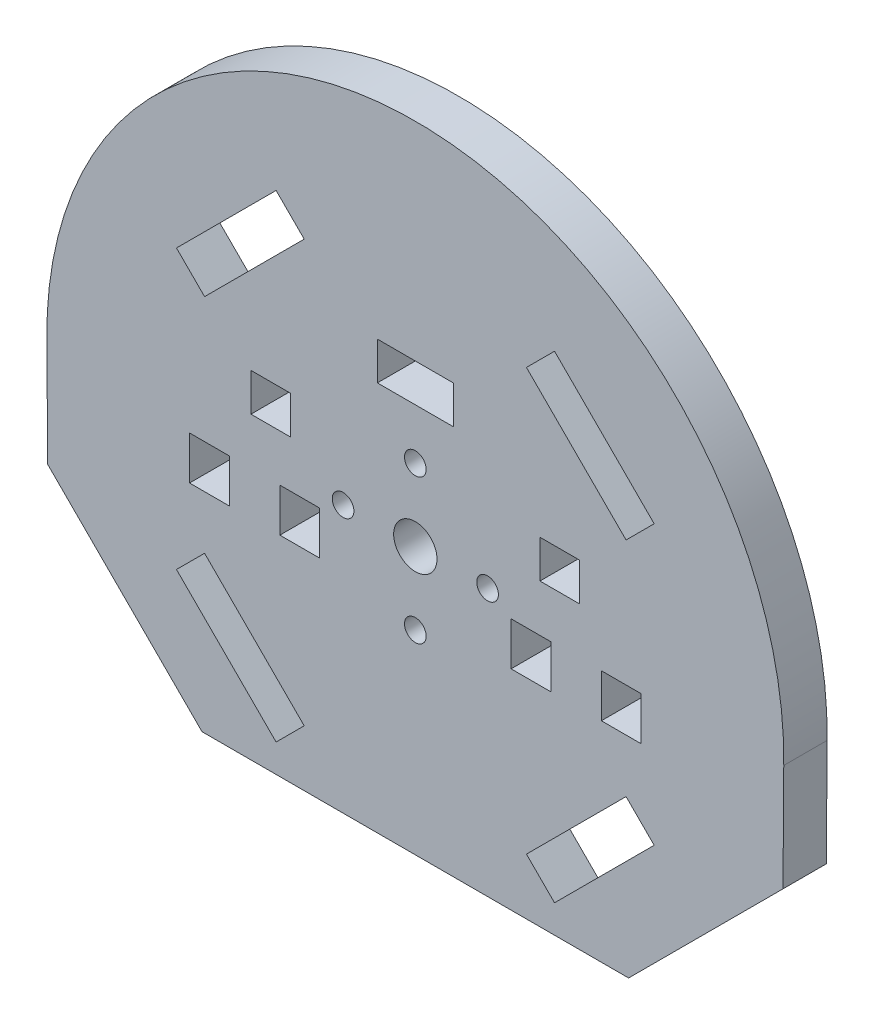
from build123d import *

# Parameters (mm, degrees)
MODEL_R             = 3
MODEL_R_2           = 1.5
MODEL_W             = 5.5
MODEL_H             = 5.25
BOSS_EXTRUDE1_DEPTH = 6


with BuildPart() as part:
    # Model → Boss-Extrude1 (new body)
    with BuildSketch(Plane.XY):
        with BuildLine():
            Line((97.092556574, 10.401311798), (38.049140345, 10.401311798))
            Line((38.049140345, 10.401311798), (16.682633066, 31.767819077))
            Line((16.682633066, 31.767819077), (16.576099155, 46.615832828))
            ThreePointArc((16.576099155, 46.615832828), (67.57084846, 98.347641115), (118.565597764, 46.615832828))
            Line((118.565597764, 46.615832828), (118.459063854, 31.767819077))
            Line((118.459063854, 31.767819077), (97.092556574, 10.401311798))
        make_face()
        with Locations((67.57084846, 47.347641115)):
            Circle(MODEL_R, mode=Mode.SUBTRACT)
        with Locations((67.57084846, 57.347641115)):
            Circle(MODEL_R_2, mode=Mode.SUBTRACT)
        with Locations((77.57084846, 47.347641115)):
            Circle(MODEL_R_2, mode=Mode.SUBTRACT)
        with Locations((67.57084846, 37.347641115)):
            Circle(MODEL_R_2, mode=Mode.SUBTRACT)
        with Locations((57.57084846, 47.347641115)):
            Circle(MODEL_R_2, mode=Mode.SUBTRACT)
        Polygon((45.296984853, 69.621504723), (52.191275969, 76.515795839), (48.302188673, 80.404883136), (34.513606439, 66.616300902), (38.402693736, 62.727213606), align=None, mode=Mode.SUBTRACT)
        Polygon((45.296984853, 25.073777508), (52.191275969, 18.179486391), (48.302188673, 14.290399095), (34.513606439, 28.078981328), (38.402693736, 31.968068624), align=None, mode=Mode.SUBTRACT)
        Polygon((89.844712067, 69.621504723), (96.739003184, 62.727213606), (100.62809048, 66.616300902), (86.839508247, 80.404883136), (82.950420951, 76.515795839), align=None, mode=Mode.SUBTRACT)
        Polygon((89.844712067, 25.073777508), (96.739003184, 31.968068624), (100.62809048, 28.078981328), (86.839508247, 14.290399095), (82.950420951, 18.179486391), align=None, mode=Mode.SUBTRACT)
        Polygon((67.57084846, 64.347641115), (72.82084846, 64.347641115), (72.82084846, 69.597641115), (62.32084846, 69.597641115), (62.32084846, 64.347641115), align=None, mode=Mode.SUBTRACT)
        Polygon((36.32084846, 42.347641115), (36.32084846, 45.347641115), (41.82084846, 45.347641115), (41.82084846, 39.347641115), (36.32084846, 39.347641115), align=None, mode=Mode.SUBTRACT)
        Polygon((54.32084846, 42.347641115), (54.32084846, 45.347641115), (48.82084846, 45.347641115), (48.82084846, 39.347641115), (54.32084846, 39.347641115), align=None, mode=Mode.SUBTRACT)
        with Locations((47.57084846, 54.472641115)):
            Rectangle(MODEL_W, MODEL_H, mode=Mode.SUBTRACT)
        Polygon((98.82084846, 42.347641115), (98.82084846, 45.347641115), (93.32084846, 45.347641115), (93.32084846, 39.347641115), (98.82084846, 39.347641115), align=None, mode=Mode.SUBTRACT)
        Polygon((80.82136419, 42.324937285), (80.82136419, 45.324937285), (86.32136419, 45.324937285), (86.32136419, 39.324937285), (80.82136419, 39.324937285), align=None, mode=Mode.SUBTRACT)
        with Locations((87.57084846, 54.472641115)):
            Rectangle(MODEL_W, MODEL_H, mode=Mode.SUBTRACT)
    extrude(amount=BOSS_EXTRUDE1_DEPTH)


solid = part.part
